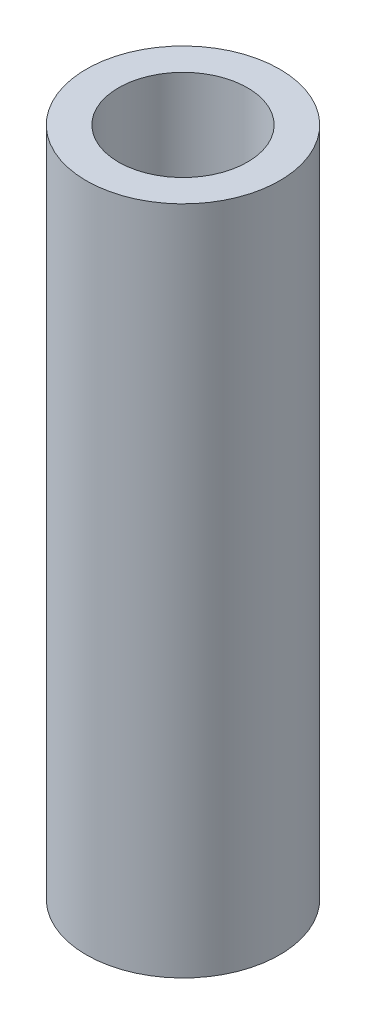
from build123d import *

# Parameters (mm, degrees)
SKETCH1_R           = 4.7625
SKETCH1_R_2         = 3.175
BOSS_EXTRUDE1_DEPTH = 33.02


with BuildPart() as part:
    # Sketch1 → Boss-Extrude1 (new body)
    with BuildSketch(Plane(origin=(0, 0, 0), x_dir=(1, 0, 0), z_dir=(0, 1, 0))):
        Circle(SKETCH1_R)
        Circle(SKETCH1_R_2, mode=Mode.SUBTRACT)
    extrude(amount=-BOSS_EXTRUDE1_DEPTH)


solid = part.part
